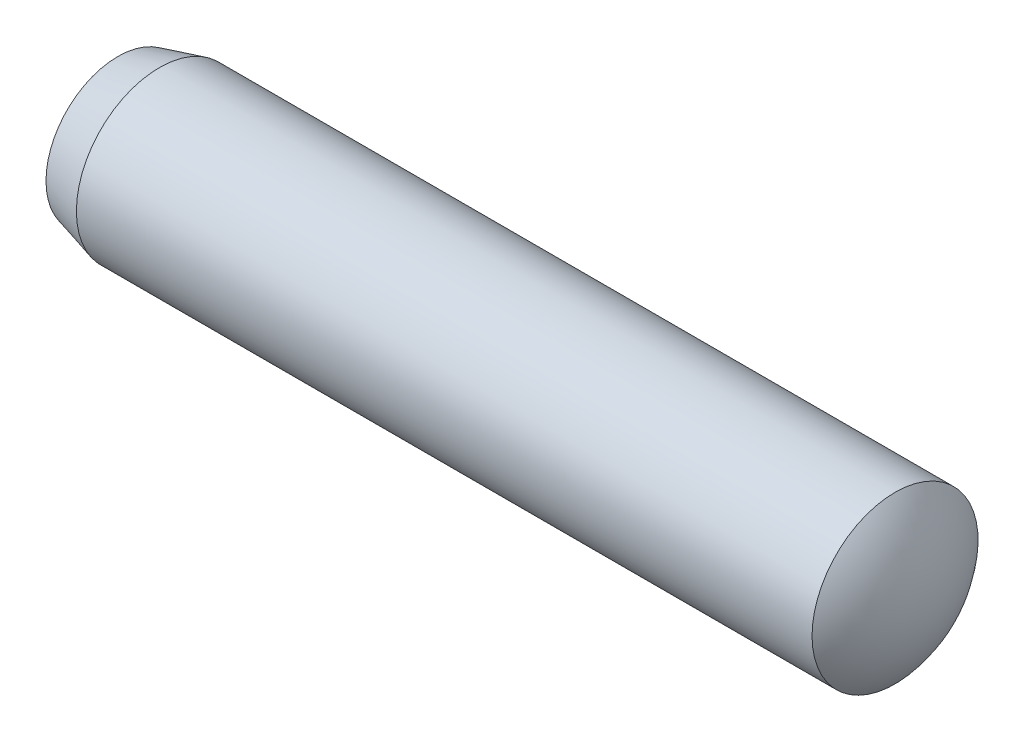
from build123d import *


with BuildPart() as part:
    # Sketch2 → Body (revolve)
    with BuildSketch(Plane.XY):
        with BuildLine():
            Line((0.767591879, 1), (9.629629176, 1))
            ThreePointArc((9.629629176, 1), (9.904432696, 0.533191932), (10, 0))
            Line((10, 0), (1.535183758, 0))
            Line((1.535183758, 0), (0, 0))
            ThreePointArc((0, 0), (0.068422763, 0.453212261), (0.267591879, 0.866025404))
            Line((0.267591879, 0.866025404), (0.767591879, 1))
        make_face()
    revolve(axis=Axis((1.535183758, 0, 0), (1, 0, 0)))


solid = part.part
